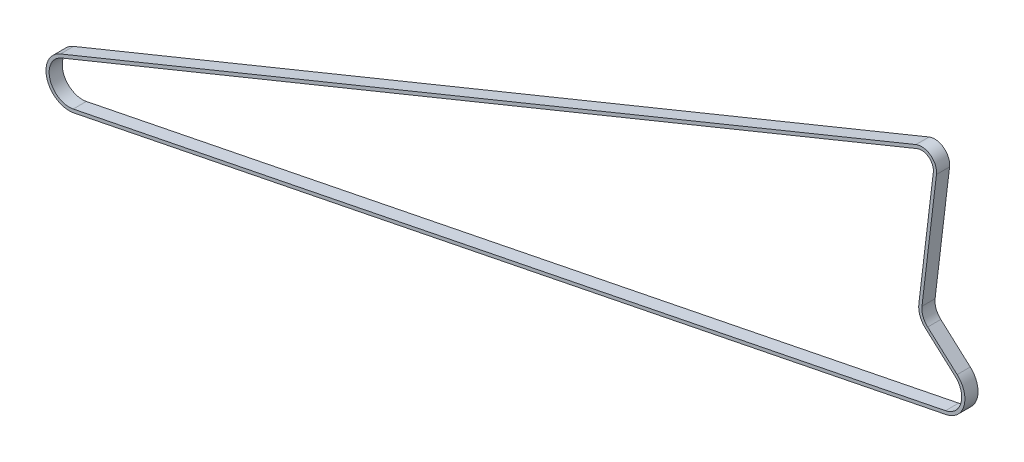
from build123d import *

# Parameters (mm, degrees)
SKETCH4_W = 6
SKETCH4_H = 1.45


with BuildPart() as part:
    # Sweep1: sweep along a path in Sketch2
    with BuildLine(Plane.XY) as sweep1_path:
        Line((6.634008087, 7.392396345), (-6.844115698, 19.487795186))
        ThreePointArc((-6.844115698, 19.487795186), (-9.188071123, 22.914875813), (-9.688379476, 27.036610909))
        Line((-9.688379476, 27.036610909), (-3.065681286, 82.544917251))
        ThreePointArc((-3.065681286, 82.544917251), (-5.437015562, 88.14522378), (-11.466030466, 88.943746635))
        Line((-11.466030466, 88.943746635), (-402.754294044, -70.804193152))
        ThreePointArc((-402.754294044, -70.804193152), (-408.510077554, -82.86635865), (-397.047352934, -89.738827246))
        Line((-397.047352934, -89.738827246), (1.95264707, -9.738827262))
        ThreePointArc((1.95264707, -9.738827262), (9.58135519, -2.618247459), (6.634008087, 7.392396345))
    # Sketch4 → Sweep1 (sweep)
    with BuildSketch(Plane(origin=(0, 0, 0), x_dir=(0, 0, 1), z_dir=(0.9804860480377625, 0.1965886812695244, 0))):
        with Locations((0, 9.932652567)):
            Rectangle(SKETCH4_W, SKETCH4_H)
    sweep(path=sweep1_path.line)


solid = part.part
